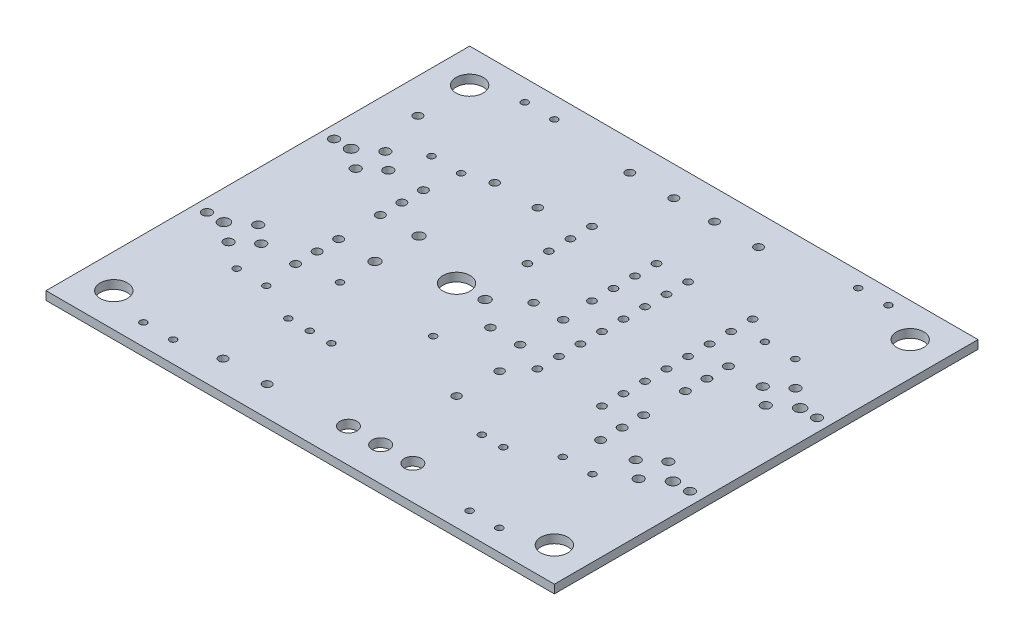
from build123d import *

# Parameters (mm, degrees)
ESQUISSE2_W      = 60
ESQUISSE2_H      = 50
ESQUISSE2_R      = 0.59944
ESQUISSE2_R_2    = 1.6002
ESQUISSE2_R_3    = 0.50038
ESQUISSE2_R_4    = 0.4826
ESQUISSE2_R_5    = 0.39878
ESQUISSE2_R_6    = 0.55118
ESQUISSE2_R_7    = 0.65024
ESQUISSE2_R_8    = 0.44958
ESQUISSE2_R_9    = 1.00076
EXTRUSION1_DEPTH = 1


with BuildPart() as part:
    # Esquisse2 → Extrusion1 (new body)
    with BuildSketch(Plane(origin=(0, 0, 0), x_dir=(1, 0, 0), z_dir=(0, 1, 0))):
        with Locations((30, 25)):
            Rectangle(ESQUISSE2_W, ESQUISSE2_H)
        with Locations(Location((16.42618, 27.59964, 0), (0, 0, 270))):  # turned: the seam where the file's is
            Circle(ESQUISSE2_R, mode=Mode.SUBTRACT)
        with Locations(Location((16.42618, 22.40026, 0), (0, 0, 270))):  # turned: the seam where the file's is
            Circle(ESQUISSE2_R, mode=Mode.SUBTRACT)
        with Locations(Location((26.82494, 25.00122, 0), (0, 0, 270))):  # turned: the seam where the file's is
            Circle(ESQUISSE2_R, mode=Mode.SUBTRACT)
        with Locations(Location((23.4696, 24.9809, 0), (0, 0, 270))):  # turned: the seam where the file's is
            Circle(ESQUISSE2_R_2, mode=Mode.SUBTRACT)
        with Locations(Location((22.60092, 3.50012, 0), (0, 0, 270))):  # turned: the seam where the file's is
            Circle(ESQUISSE2_R_3, mode=Mode.SUBTRACT)
        with Locations(Location((17.399, 3.50012, 0), (0, 0, 270))):  # turned: the seam where the file's is
            Circle(ESQUISSE2_R_3, mode=Mode.SUBTRACT)
        with Locations(Location((29.99994, 27.54122, 0), (0, 0, 270))):  # turned: the seam where the file's is
            Circle(ESQUISSE2_R_4, mode=Mode.SUBTRACT)
        with Locations(Location((29.99994, 22.46122, 0), (0, 0, 270))):  # turned: the seam where the file's is
            Circle(ESQUISSE2_R_4, mode=Mode.SUBTRACT)
        with Locations(Location((33.50006, 27.54122, 0), (0, 0, 270))):  # turned: the seam where the file's is
            Circle(ESQUISSE2_R_4, mode=Mode.SUBTRACT)
        with Locations(Location((33.50006, 22.46122, 0), (0, 0, 270))):  # turned: the seam where the file's is
            Circle(ESQUISSE2_R_4, mode=Mode.SUBTRACT)
        with Locations(Location((15.46098, 37.50056, 0), (0, 0, 270))):  # turned: the seam where the file's is
            Circle(ESQUISSE2_R_4, mode=Mode.SUBTRACT)
        with Locations(Location((20.54098, 37.50056, 0), (0, 0, 270))):  # turned: the seam where the file's is
            Circle(ESQUISSE2_R_4, mode=Mode.SUBTRACT)
        with Locations(Location((35.0012, 13.45946, 0), (0, 0, 270))):  # turned: the seam where the file's is
            Circle(ESQUISSE2_R_4, mode=Mode.SUBTRACT)
        with Locations(Location((35.0012, 18.53946, 0), (0, 0, 270))):  # turned: the seam where the file's is
            Circle(ESQUISSE2_R_4, mode=Mode.SUBTRACT)
        with Locations(Location((42.99458, 10.99058, 0), (0, 0, 270))):  # turned: the seam where the file's is
            Circle(ESQUISSE2_R_5, mode=Mode.SUBTRACT)
        with Locations(Location((40.45458, 10.99058, 0), (0, 0, 270))):  # turned: the seam where the file's is
            Circle(ESQUISSE2_R_5, mode=Mode.SUBTRACT)
        with Locations(Location((1.4986, 32.50184, 0), (0, 0, 270))):  # turned: the seam where the file's is
            Circle(ESQUISSE2_R_6, mode=Mode.SUBTRACT)
        with Locations(Location((7.8994, 32.50184, 0), (0, 0, 270))):  # turned: the seam where the file's is
            Circle(ESQUISSE2_R_6, mode=Mode.SUBTRACT)
        with Locations(Location((5.79882, 30.75178, 0), (0, 0, 270))):  # turned: the seam where the file's is
            Circle(ESQUISSE2_R_6, mode=Mode.SUBTRACT)
        with Locations(Location((5.79882, 34.2519, 0), (0, 0, 270))):  # turned: the seam where the file's is
            Circle(ESQUISSE2_R_6, mode=Mode.SUBTRACT)
        with Locations(Location((3.50012, 32.50184, 0), (0, 0, 270))):  # turned: the seam where the file's is
            Circle(ESQUISSE2_R_7, mode=Mode.SUBTRACT)
        with Locations(Location((1.4986, 17.5006, 0), (0, 0, 270))):  # turned: the seam where the file's is
            Circle(ESQUISSE2_R_6, mode=Mode.SUBTRACT)
        with Locations(Location((7.8994, 17.5006, 0), (0, 0, 270))):  # turned: the seam where the file's is
            Circle(ESQUISSE2_R_6, mode=Mode.SUBTRACT)
        with Locations(Location((5.79882, 15.75054, 0), (0, 0, 270))):  # turned: the seam where the file's is
            Circle(ESQUISSE2_R_6, mode=Mode.SUBTRACT)
        with Locations(Location((5.79882, 19.25066, 0), (0, 0, 270))):  # turned: the seam where the file's is
            Circle(ESQUISSE2_R_6, mode=Mode.SUBTRACT)
        with Locations(Location((3.50012, 17.5006, 0), (0, 0, 270))):  # turned: the seam where the file's is
            Circle(ESQUISSE2_R_7, mode=Mode.SUBTRACT)
        with Locations(Location((58.50128, 32.4993, 0), (0, 0, 270))):  # turned: the seam where the file's is
            Circle(ESQUISSE2_R_6, mode=Mode.SUBTRACT)
        with Locations(Location((52.10048, 32.4993, 0), (0, 0, 270))):  # turned: the seam where the file's is
            Circle(ESQUISSE2_R_6, mode=Mode.SUBTRACT)
        with Locations(Location((54.20106, 34.24936, 0), (0, 0, 270))):  # turned: the seam where the file's is
            Circle(ESQUISSE2_R_6, mode=Mode.SUBTRACT)
        with Locations(Location((54.20106, 30.74924, 0), (0, 0, 270))):  # turned: the seam where the file's is
            Circle(ESQUISSE2_R_6, mode=Mode.SUBTRACT)
        with Locations(Location((56.49976, 32.4993, 0), (0, 0, 270))):  # turned: the seam where the file's is
            Circle(ESQUISSE2_R_7, mode=Mode.SUBTRACT)
        with Locations(Location((58.50128, 17.49806, 0), (0, 0, 270))):  # turned: the seam where the file's is
            Circle(ESQUISSE2_R_6, mode=Mode.SUBTRACT)
        with Locations(Location((52.10048, 17.49806, 0), (0, 0, 270))):  # turned: the seam where the file's is
            Circle(ESQUISSE2_R_6, mode=Mode.SUBTRACT)
        with Locations(Location((54.20106, 19.24812, 0), (0, 0, 270))):  # turned: the seam where the file's is
            Circle(ESQUISSE2_R_6, mode=Mode.SUBTRACT)
        with Locations(Location((54.20106, 15.748, 0), (0, 0, 270))):  # turned: the seam where the file's is
            Circle(ESQUISSE2_R_6, mode=Mode.SUBTRACT)
        with Locations(Location((56.49976, 17.49806, 0), (0, 0, 270))):  # turned: the seam where the file's is
            Circle(ESQUISSE2_R_7, mode=Mode.SUBTRACT)
        with Locations(Location((4.0005, 45.9994, 0), (0, 0, 270))):  # turned: the seam where the file's is
            Circle(ESQUISSE2_R_2, mode=Mode.SUBTRACT)
        with Locations(Location((55.99938, 45.9994, 0), (0, 0, 270))):  # turned: the seam where the file's is
            Circle(ESQUISSE2_R_2, mode=Mode.SUBTRACT)
        with Locations(Location((55.99938, 4.0005, 0), (0, 0, 270))):  # turned: the seam where the file's is
            Circle(ESQUISSE2_R_2, mode=Mode.SUBTRACT)
        with Locations(Location((4.0005, 4.0005, 0), (0, 0, 270))):  # turned: the seam where the file's is
            Circle(ESQUISSE2_R_2, mode=Mode.SUBTRACT)
        with Locations(Location((25.64892, 38.78834, 0), (0, 0, 270))):  # turned: the seam where the file's is
            Circle(ESQUISSE2_R_8, mode=Mode.SUBTRACT)
        with Locations(Location((25.64892, 36.24834, 0), (0, 0, 270))):  # turned: the seam where the file's is
            Circle(ESQUISSE2_R_8, mode=Mode.SUBTRACT)
        with Locations(Location((25.64892, 33.70834, 0), (0, 0, 270))):  # turned: the seam where the file's is
            Circle(ESQUISSE2_R_8, mode=Mode.SUBTRACT)
        with Locations(Location((25.64892, 31.16834, 0), (0, 0, 270))):  # turned: the seam where the file's is
            Circle(ESQUISSE2_R_8, mode=Mode.SUBTRACT)
        with Locations(Location((33.26892, 31.16834, 0), (0, 0, 270))):  # turned: the seam where the file's is
            Circle(ESQUISSE2_R_8, mode=Mode.SUBTRACT)
        with Locations(Location((33.26892, 33.70834, 0), (0, 0, 270))):  # turned: the seam where the file's is
            Circle(ESQUISSE2_R_8, mode=Mode.SUBTRACT)
        with Locations(Location((33.26892, 36.24834, 0), (0, 0, 270))):  # turned: the seam where the file's is
            Circle(ESQUISSE2_R_8, mode=Mode.SUBTRACT)
        with Locations(Location((33.26892, 38.78834, 0), (0, 0, 270))):  # turned: the seam where the file's is
            Circle(ESQUISSE2_R_8, mode=Mode.SUBTRACT)
        with Locations(Location((36.99256, 38.7858, 0), (0, 0, 270))):  # turned: the seam where the file's is
            Circle(ESQUISSE2_R_8, mode=Mode.SUBTRACT)
        with Locations(Location((36.99256, 36.2458, 0), (0, 0, 270))):  # turned: the seam where the file's is
            Circle(ESQUISSE2_R_8, mode=Mode.SUBTRACT)
        with Locations(Location((36.99256, 33.7058, 0), (0, 0, 270))):  # turned: the seam where the file's is
            Circle(ESQUISSE2_R_8, mode=Mode.SUBTRACT)
        with Locations(Location((36.99256, 31.1658, 0), (0, 0, 270))):  # turned: the seam where the file's is
            Circle(ESQUISSE2_R_8, mode=Mode.SUBTRACT)
        with Locations(Location((36.99256, 28.6258, 0), (0, 0, 270))):  # turned: the seam where the file's is
            Circle(ESQUISSE2_R_8, mode=Mode.SUBTRACT)
        with Locations(Location((36.99256, 26.0858, 0), (0, 0, 270))):  # turned: the seam where the file's is
            Circle(ESQUISSE2_R_8, mode=Mode.SUBTRACT)
        with Locations(Location((36.99256, 23.5458, 0), (0, 0, 270))):  # turned: the seam where the file's is
            Circle(ESQUISSE2_R_8, mode=Mode.SUBTRACT)
        with Locations(Location((36.99256, 21.0058, 0), (0, 0, 270))):  # turned: the seam where the file's is
            Circle(ESQUISSE2_R_8, mode=Mode.SUBTRACT)
        with Locations(Location((44.61256, 21.0058, 0), (0, 0, 270))):  # turned: the seam where the file's is
            Circle(ESQUISSE2_R_8, mode=Mode.SUBTRACT)
        with Locations(Location((44.61256, 23.5458, 0), (0, 0, 270))):  # turned: the seam where the file's is
            Circle(ESQUISSE2_R_8, mode=Mode.SUBTRACT)
        with Locations(Location((44.61256, 26.0858, 0), (0, 0, 270))):  # turned: the seam where the file's is
            Circle(ESQUISSE2_R_8, mode=Mode.SUBTRACT)
        with Locations(Location((44.61256, 28.6258, 0), (0, 0, 270))):  # turned: the seam where the file's is
            Circle(ESQUISSE2_R_8, mode=Mode.SUBTRACT)
        with Locations(Location((44.61256, 31.1658, 0), (0, 0, 270))):  # turned: the seam where the file's is
            Circle(ESQUISSE2_R_8, mode=Mode.SUBTRACT)
        with Locations(Location((44.61256, 33.7058, 0), (0, 0, 270))):  # turned: the seam where the file's is
            Circle(ESQUISSE2_R_8, mode=Mode.SUBTRACT)
        with Locations(Location((44.61256, 36.2458, 0), (0, 0, 270))):  # turned: the seam where the file's is
            Circle(ESQUISSE2_R_8, mode=Mode.SUBTRACT)
        with Locations(Location((44.61256, 38.7858, 0), (0, 0, 270))):  # turned: the seam where the file's is
            Circle(ESQUISSE2_R_8, mode=Mode.SUBTRACT)
        with Locations(Location((17.145, 11.46048, 0), (0, 0, 270))):  # turned: the seam where the file's is
            Circle(ESQUISSE2_R_5, mode=Mode.SUBTRACT)
        with Locations(Location((19.685, 11.46048, 0), (0, 0, 270))):  # turned: the seam where the file's is
            Circle(ESQUISSE2_R_5, mode=Mode.SUBTRACT)
        with Locations(Location((22.225, 11.46048, 0), (0, 0, 270))):  # turned: the seam where the file's is
            Circle(ESQUISSE2_R_5, mode=Mode.SUBTRACT)
        with Locations(Location((22.40026, 46.49978, 0), (0, 0, 270))):  # turned: the seam where the file's is
            Circle(ESQUISSE2_R_3, mode=Mode.SUBTRACT)
        with Locations(Location((27.59964, 46.49978, 0), (0, 0, 270))):  # turned: the seam where the file's is
            Circle(ESQUISSE2_R_3, mode=Mode.SUBTRACT)
        with Locations(Location((32.40024, 46.49978, 0), (0, 0, 270))):  # turned: the seam where the file's is
            Circle(ESQUISSE2_R_3, mode=Mode.SUBTRACT)
        with Locations(Location((37.59962, 46.49978, 0), (0, 0, 270))):  # turned: the seam where the file's is
            Circle(ESQUISSE2_R_3, mode=Mode.SUBTRACT)
        with Locations(Location((8.99922, 36.4998, 0), (0, 0, 270))):  # turned: the seam where the file's is
            Circle(ESQUISSE2_R_5, mode=Mode.SUBTRACT)
        with Locations(Location((8.99922, 47.50054, 0), (0, 0, 270))):  # turned: the seam where the file's is
            Circle(ESQUISSE2_R_5, mode=Mode.SUBTRACT)
        with Locations(Location((12.49934, 13.5001, 0), (0, 0, 270))):  # turned: the seam where the file's is
            Circle(ESQUISSE2_R_5, mode=Mode.SUBTRACT)
        with Locations(Location((12.49934, 2.49936, 0), (0, 0, 270))):  # turned: the seam where the file's is
            Circle(ESQUISSE2_R_5, mode=Mode.SUBTRACT)
        with Locations(Location((8.99922, 13.5001, 0), (0, 0, 270))):  # turned: the seam where the file's is
            Circle(ESQUISSE2_R_5, mode=Mode.SUBTRACT)
        with Locations(Location((8.99922, 2.49936, 0), (0, 0, 270))):  # turned: the seam where the file's is
            Circle(ESQUISSE2_R_5, mode=Mode.SUBTRACT)
        with Locations(Location((47.50054, 2.49936, 0), (0, 0, 270))):  # turned: the seam where the file's is
            Circle(ESQUISSE2_R_5, mode=Mode.SUBTRACT)
        with Locations(Location((47.50054, 13.5001, 0), (0, 0, 270))):  # turned: the seam where the file's is
            Circle(ESQUISSE2_R_5, mode=Mode.SUBTRACT)
        with Locations(Location((51.00066, 13.5001, 0), (0, 0, 270))):  # turned: the seam where the file's is
            Circle(ESQUISSE2_R_5, mode=Mode.SUBTRACT)
        with Locations(Location((51.00066, 2.49936, 0), (0, 0, 270))):  # turned: the seam where the file's is
            Circle(ESQUISSE2_R_5, mode=Mode.SUBTRACT)
        with Locations(Location((12.49934, 36.4998, 0), (0, 0, 270))):  # turned: the seam where the file's is
            Circle(ESQUISSE2_R_5, mode=Mode.SUBTRACT)
        with Locations(Location((12.49934, 47.50054, 0), (0, 0, 270))):  # turned: the seam where the file's is
            Circle(ESQUISSE2_R_5, mode=Mode.SUBTRACT)
        with Locations(Location((47.6631, 37.19068, 0), (0, 0, 270))):  # turned: the seam where the file's is
            Circle(ESQUISSE2_R_5, mode=Mode.SUBTRACT)
        with Locations(Location((47.6631, 48.19142, 0), (0, 0, 270))):  # turned: the seam where the file's is
            Circle(ESQUISSE2_R_5, mode=Mode.SUBTRACT)
        with Locations(Location((51.20132, 37.22624, 0), (0, 0, 270))):  # turned: the seam where the file's is
            Circle(ESQUISSE2_R_5, mode=Mode.SUBTRACT)
        with Locations(Location((51.20132, 48.22698, 0), (0, 0, 270))):  # turned: the seam where the file's is
            Circle(ESQUISSE2_R_5, mode=Mode.SUBTRACT)
        with Locations(Location((16.49984, 18.1991, 0), (0, 0, 270))):  # turned: the seam where the file's is
            Circle(ESQUISSE2_R_5, mode=Mode.SUBTRACT)
        with Locations(Location((27.50058, 18.1991, 0), (0, 0, 270))):  # turned: the seam where the file's is
            Circle(ESQUISSE2_R_5, mode=Mode.SUBTRACT)
        with Locations(Location((35.49904, 4.0005, 0), (0, 0, 270))):  # turned: the seam where the file's is
            Circle(ESQUISSE2_R_9, mode=Mode.SUBTRACT)
        with Locations(Location((39.29888, 4.0005, 0), (0, 0, 270))):  # turned: the seam where the file's is
            Circle(ESQUISSE2_R_9, mode=Mode.SUBTRACT)
        with Locations(Location((31.6992, 4.0005, 0), (0, 0, 270))):  # turned: the seam where the file's is
            Circle(ESQUISSE2_R_9, mode=Mode.SUBTRACT)
        with Locations(Location((11.99896, 27.45994, 0), (0, 0, 270))):  # turned: the seam where the file's is
            Circle(ESQUISSE2_R_3, mode=Mode.SUBTRACT)
        with Locations(Location((11.99896, 29.99994, 0), (0, 0, 270))):  # turned: the seam where the file's is
            Circle(ESQUISSE2_R_3, mode=Mode.SUBTRACT)
        with Locations(Location((11.99896, 32.53994, 0), (0, 0, 270))):  # turned: the seam where the file's is
            Circle(ESQUISSE2_R_3, mode=Mode.SUBTRACT)
        with Locations(Location((11.99896, 17.45996, 0), (0, 0, 270))):  # turned: the seam where the file's is
            Circle(ESQUISSE2_R_3, mode=Mode.SUBTRACT)
        with Locations(Location((11.99896, 19.99996, 0), (0, 0, 270))):  # turned: the seam where the file's is
            Circle(ESQUISSE2_R_3, mode=Mode.SUBTRACT)
        with Locations(Location((11.99896, 22.53996, 0), (0, 0, 270))):  # turned: the seam where the file's is
            Circle(ESQUISSE2_R_3, mode=Mode.SUBTRACT)
        with Locations(Location((48.00092, 27.45994, 0), (0, 0, 270))):  # turned: the seam where the file's is
            Circle(ESQUISSE2_R_3, mode=Mode.SUBTRACT)
        with Locations(Location((48.00092, 29.99994, 0), (0, 0, 270))):  # turned: the seam where the file's is
            Circle(ESQUISSE2_R_3, mode=Mode.SUBTRACT)
        with Locations(Location((48.00092, 32.53994, 0), (0, 0, 270))):  # turned: the seam where the file's is
            Circle(ESQUISSE2_R_3, mode=Mode.SUBTRACT)
        with Locations(Location((48.00092, 17.45996, 0), (0, 0, 270))):  # turned: the seam where the file's is
            Circle(ESQUISSE2_R_3, mode=Mode.SUBTRACT)
        with Locations(Location((48.00092, 19.99996, 0), (0, 0, 270))):  # turned: the seam where the file's is
            Circle(ESQUISSE2_R_3, mode=Mode.SUBTRACT)
        with Locations(Location((48.00092, 22.53996, 0), (0, 0, 270))):  # turned: the seam where the file's is
            Circle(ESQUISSE2_R_3, mode=Mode.SUBTRACT)
        with Locations(Location((4.0767, 39.81958, 0), (0, 0, 270))):  # turned: the seam where the file's is
            Circle(ESQUISSE2_R_3, mode=Mode.SUBTRACT)
    extrude(amount=EXTRUSION1_DEPTH)


solid = part.part
